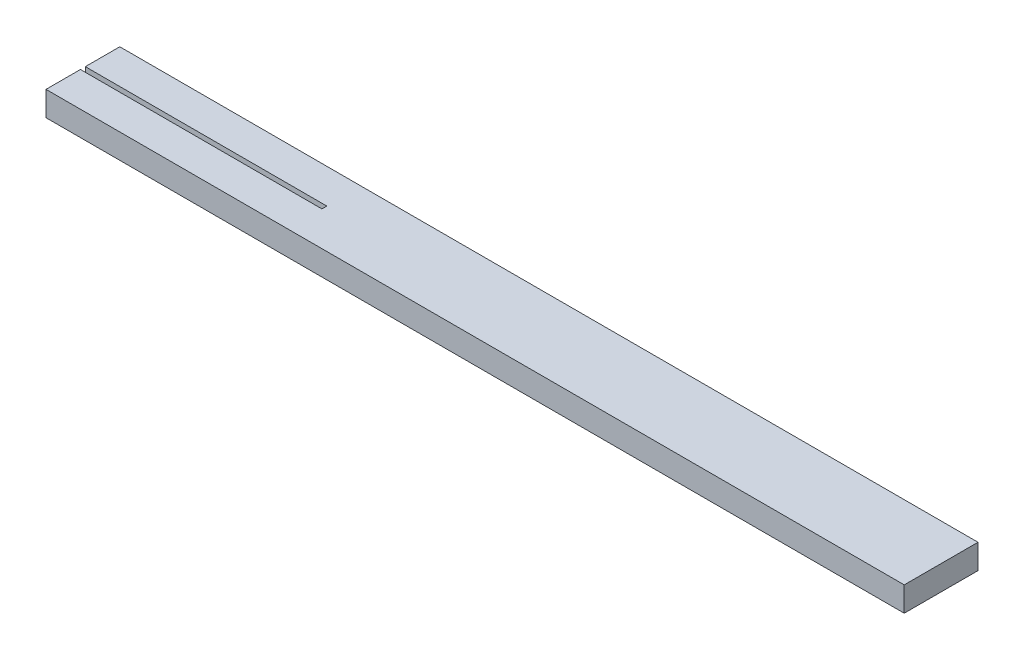
from build123d import *

# Parameters (mm, degrees)
EXTRUDE_1_DEPTH = 1


with BuildPart() as part:
    # 草图1 → 凸台-拉伸1 (new body)
    with BuildSketch(Plane(origin=(0, 1, 0), x_dir=(1, 0, 0), z_dir=(0, 1, 0))):
        Polygon((-7.219213296, 5.813036566), (-7.219213296, 5.613036566), (-17.039213296, 5.613036566), (-17.039213296, 4.213036566), (-4.189213296, 4.213036566), (-2.853689485, 4.213036566), (17.860786704, 4.213036566), (17.860786704, 7.213036566), (-4.94779194, 7.213036566), (-5.089213296, 7.213036566), (-17.039213296, 7.213036566), (-17.039213296, 5.813036566), align=None)
    extrude(amount=-EXTRUDE_1_DEPTH)


solid = part.part
